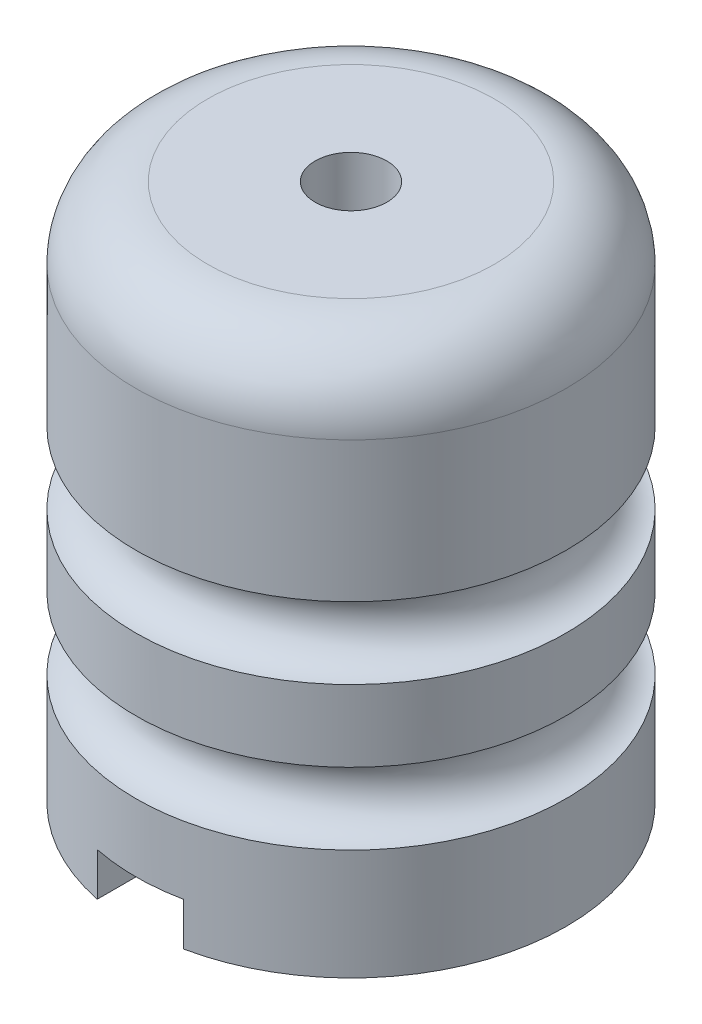
from build123d import *

# Parameters (mm, degrees)
SKETCH2_R          = 5
SKETCH3_R          = 5
CUT_EXTRUDE1_DEPTH = 76
SKETCH4_R          = 22.261929886
CUT_EXTRUDE2_DEPTH = 20
SKETCH5_W          = 12
SKETCH5_H          = 6
CUT_EXTRUDE3_DEPTH = 35


with BuildPart() as part:
    # Sketch1 → Revolve1 (revolve)
    with BuildSketch(Plane.XY):
        with BuildLine():
            Line((0, -40.450423349), (0, 34.549576651))
            Line((0, 34.549576651), (20, 34.549576651))
            ThreePointArc((20, 34.549576651), (27.071067812, 31.620644463), (30, 24.549576651))
            Line((30, 24.549576651), (30, -40.450423349))
            Line((30, -40.450423349), (0, -40.450423349))
        make_face()
    revolve(axis=Axis((0, -40.450423349, 0), (0, 1, 0)))

    # Sketch2 → Cut-Revolve1 (revolve, cut)
    with BuildSketch(Plane.XY):
        with Locations((30, 0)):
            Circle(SKETCH2_R)
        with Locations((30, -20)):
            Circle(SKETCH2_R)
    revolve(axis=Axis((0, -46.378397734, 0), (0, 1, 0)), mode=Mode.SUBTRACT)

    # Sketch3 → Cut-Extrude1 (cut, through all)
    with BuildSketch(Plane(origin=(0, 34.549576651, 0), x_dir=(1, 0, 0), z_dir=(0, 1, 0))):
        Circle(SKETCH3_R)
    extrude(amount=-CUT_EXTRUDE1_DEPTH, mode=Mode.SUBTRACT)

    # Sketch4 → Cut-Extrude2 (cut)
    with BuildSketch(Plane.XZ.offset(40.450423349)):
        Circle(SKETCH4_R)
    extrude(amount=-CUT_EXTRUDE2_DEPTH, mode=Mode.SUBTRACT)

    # Sketch5 → Cut-Extrude3 (cut, symmetric)
    with BuildSketch(Plane.XY):
        with Locations((0, -37.450423349)):
            Rectangle(SKETCH5_W, SKETCH5_H)
    extrude(amount=CUT_EXTRUDE3_DEPTH, both=True, mode=Mode.SUBTRACT)


solid = part.part
